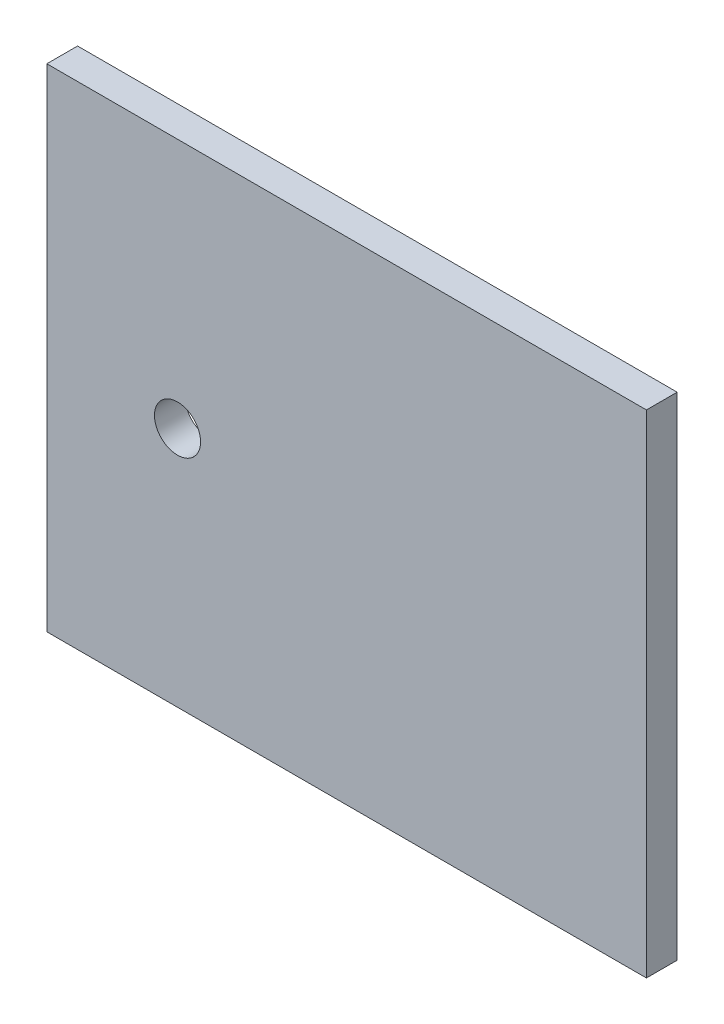
from build123d import *

# Parameters (mm, degrees)
SKETCH1_W           = 39
SKETCH1_H           = 32
SKETCH1_R           = 1.5
BOSS_EXTRUDE1_DEPTH = 2


with BuildPart() as part:
    # Sketch1 → Boss-Extrude1 (new body)
    with BuildSketch(Plane.XY):
        with Locations((19.5, 16)):
            Rectangle(SKETCH1_W, SKETCH1_H)
        with Locations((8.5, 15.7)):
            Circle(SKETCH1_R, mode=Mode.SUBTRACT)
    extrude(amount=BOSS_EXTRUDE1_DEPTH)


solid = part.part
